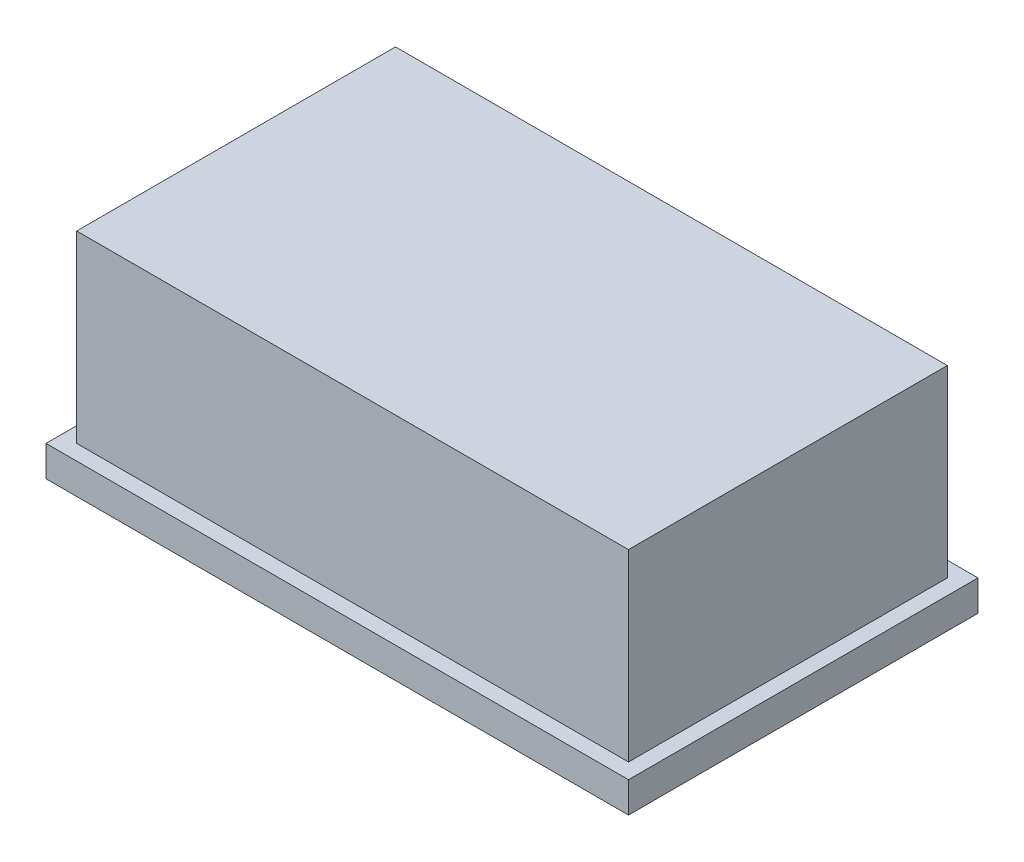
from build123d import *

# Parameters (mm, degrees)
SKETCH_1_W          = 47.5
SKETCH_1_H          = 28.5
EXTRUDE_1_DEPTH     = 2.5
SKETCH_2_W          = 45
SKETCH_2_H          = 26
EXTRUDE_2_DEPTH     = 15
SKETCH_3_W          = 36
SKETCH_3_H          = 18
CUT_EXTRUDE_1_DEPTH = 3
CHAMFER_1_SIZE      = 2


with BuildPart() as part:
    # 草图1 → 凸台-拉伸1 (new body)
    with BuildSketch(Plane(origin=(0, 0, 0), x_dir=(1, 0, 0), z_dir=(0, 1, 0))):
        with Locations((23.75, 14.25)):
            Rectangle(SKETCH_1_W, SKETCH_1_H)
    extrude(amount=EXTRUDE_1_DEPTH)

    # 草图2 → 凸台-拉伸2 (add)
    with BuildSketch(Plane(origin=(0, 2.5, 0), x_dir=(1, 0, 0), z_dir=(0, 1, 0))):
        with Locations((23.75, 14.25)):
            Rectangle(SKETCH_2_W, SKETCH_2_H)
    extrude(amount=EXTRUDE_2_DEPTH)

    # 草图3 → 切除-拉伸1 (cut)
    with BuildSketch(Plane.XZ):
        with Locations((23.75, -14.25)):
            Rectangle(SKETCH_3_W, SKETCH_3_H)
    extrude(amount=-CUT_EXTRUDE_1_DEPTH, mode=Mode.SUBTRACT)

    # 倒角1
    chamfer_1_edges = [part.edges().sort_by_distance(p)[0] for p in [
        (41.75, 0, -14.25),
        (23.75, 0, -5.25),
        (5.75, 0, -14.25),
        (23.75, 0, -23.25),
    ]]
    chamfer(chamfer_1_edges, length=CHAMFER_1_SIZE)


solid = part.part
